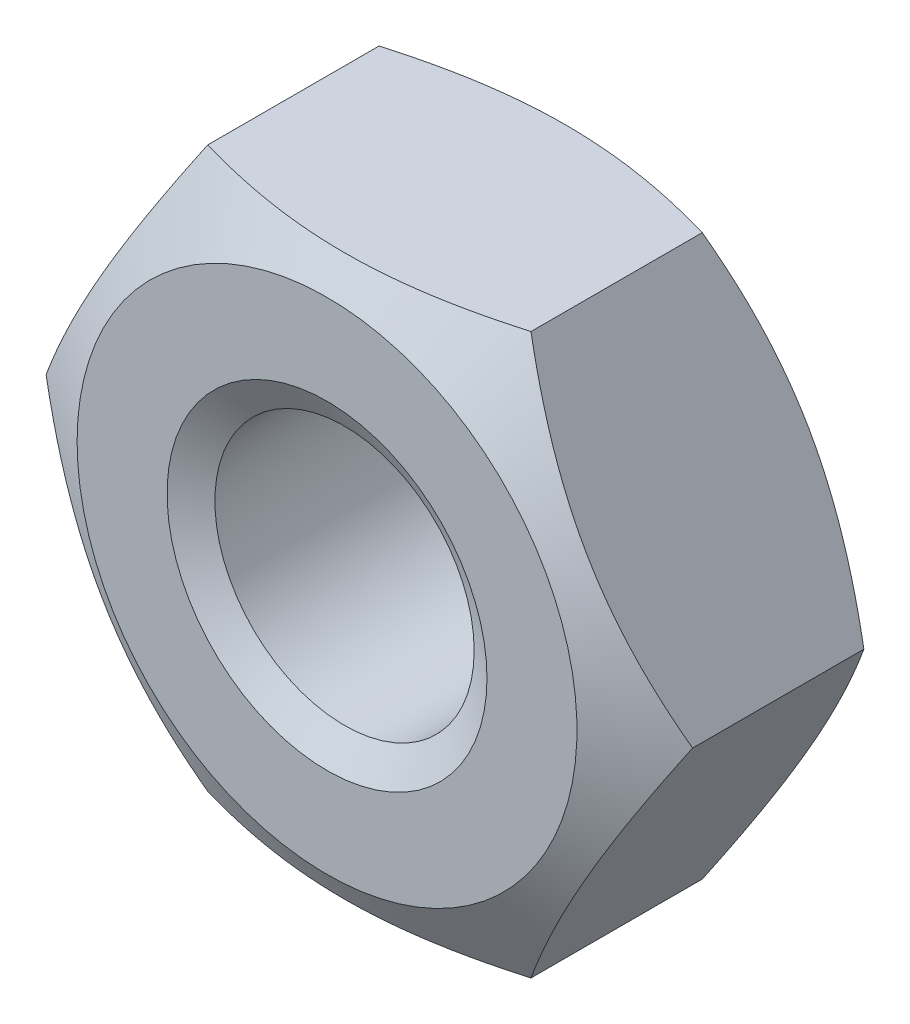
from build123d import *

# Parameters (mm, degrees)
SKETCH1_R               = 1.621
BASENUT_DEPTH           = 3.2
ENDCHAMFER_SIZE         = 0.379
ENDCHAMFER_SIZE2        = 0.218815752
ENDCHAMFER_PART_2_SIZE  = 0.379
ENDCHAMFER_PART_2_SIZE2 = 0.218815752


with BuildPart() as part:
    # Sketch1 → BaseNut (new body)
    with BuildSketch(Plane.XY):
        Polygon((4.041451884, 0), (2.020725942, 3.5), (-2.020725942, 3.5), (-4.041451884, 0), (-2.020725942, -3.5), (2.020725942, -3.5), align=None)
        Circle(SKETCH1_R, mode=Mode.SUBTRACT)
    extrude(amount=-BASENUT_DEPTH)

    # Sketch2 → Double-Chamfer (revolve, cut)
    with BuildSketch(Plane(origin=(0, 0, 0), x_dir=(1, 0, 0), z_dir=(0, 1, 0))):
        Polygon((-4.041451884, 3.2), (-3.125, 3.2), (-4.041451884, 2.670886258), align=None)
        Polygon((-4.041451884, 0.529113742), (-4.041451884, 0), (-3.125, 0), align=None)
    revolve(axis=Axis((0, 0, -3.375940562), (0, 0, 1)), mode=Mode.SUBTRACT)

    # EndChamfer
    endchamfer_edges = [part.edges().sort_by_distance(p)[0] for p in [
        (-1.621, 0, -3.2),
    ]]
    endchamfer_side = [part.faces().sort_by_distance(p)[0] for p in [
        (-1.621, 0, -1.6),
    ]]
    chamfer(endchamfer_edges, length=ENDCHAMFER_SIZE, length2=ENDCHAMFER_SIZE2, reference=endchamfer_side[0])

    # EndChamfer part 2
    endchamfer_part_2_edges = [part.edges().sort_by_distance(p)[0] for p in [
        (-1.621, 0, 0),
    ]]
    endchamfer_part_2_side = [part.faces().sort_by_distance(p)[0] for p in [
        (3.036611652, 0, 0),
    ]]
    chamfer(endchamfer_part_2_edges, length=ENDCHAMFER_PART_2_SIZE, length2=ENDCHAMFER_PART_2_SIZE2, reference=endchamfer_part_2_side[0])


solid = part.part
